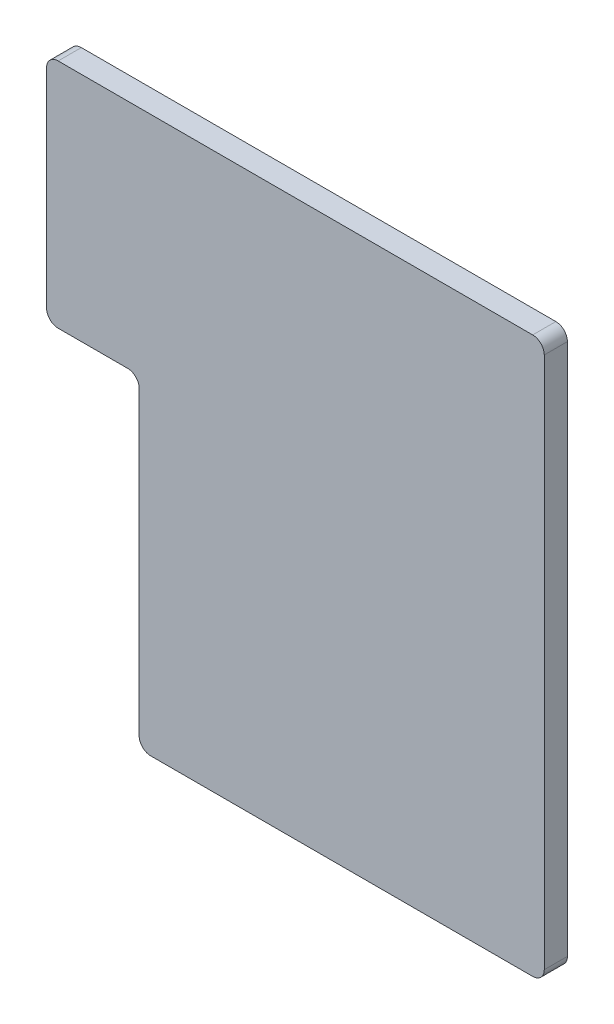
from build123d import *

# Parameters (mm, degrees)
EXTRUDE_1_DEPTH = 1


with BuildPart() as part:
    # 草图1 → 凸台-拉伸1 (new body)
    with BuildSketch(Plane.XY):
        with BuildLine():
            Line((1.5, 24), (-3.5, 24))
            ThreePointArc((-3.5, 24), (-3.853553391, 23.853553391), (-4, 23.5))
            Line((-4, 23.5), (-4, 14.5))
            ThreePointArc((-4, 14.5), (-3.853553391, 14.146446609), (-3.5, 14))
            Line((-3.5, 14), (-0.5, 14))
            ThreePointArc((-0.5, 14), (-0.146446609, 13.853553391), (0, 13.5))
            Line((0, 13.5), (0, 0.5))
            ThreePointArc((0, 0.5), (0.146446609, 0.146446609), (0.5, 0))
            Line((0.5, 0), (17, 0))
            ThreePointArc((17, 0), (17.353553391, 0.146446609), (17.5, 0.5))
            Line((17.5, 0.5), (17.5, 23.5))
            ThreePointArc((17.5, 23.5), (17.353553391, 23.853553391), (17, 24))
            Line((17, 24), (1.5, 24))
        make_face()
    extrude(amount=EXTRUDE_1_DEPTH)


solid = part.part
